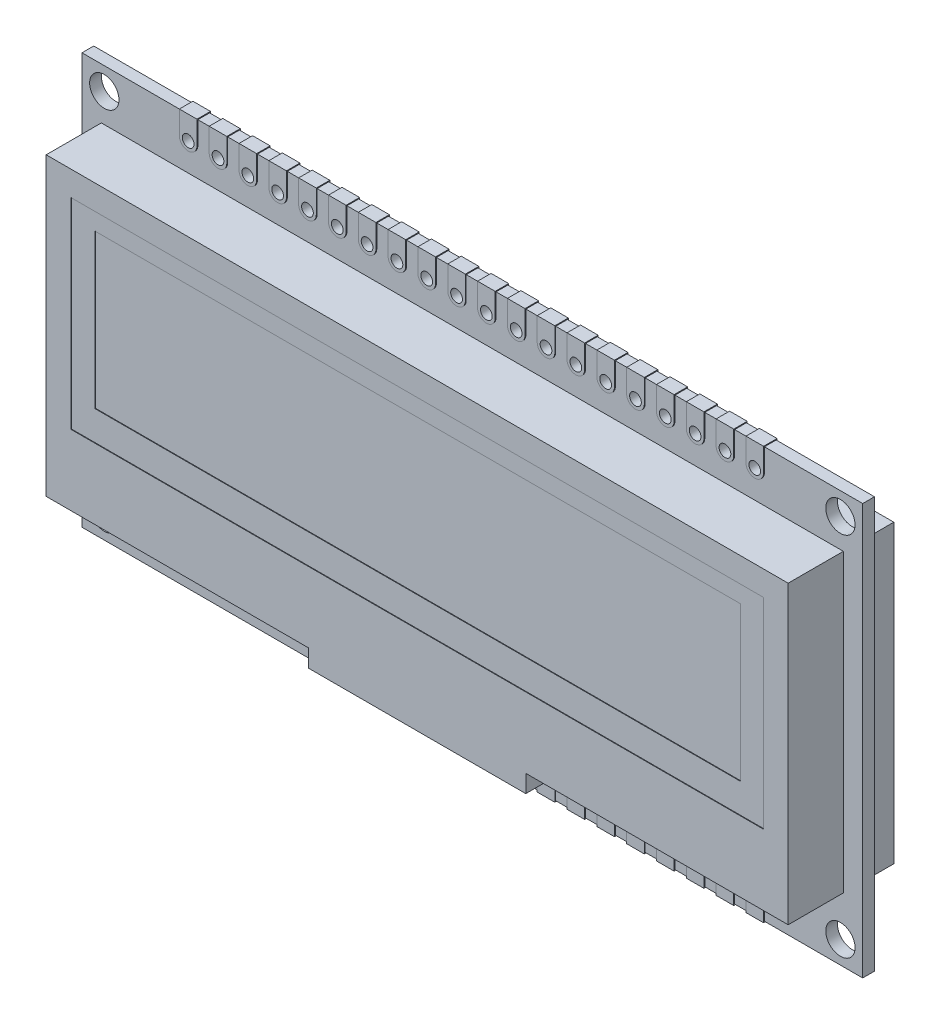
from build123d import *

# Parameters (mm, degrees)
SKETCH1_W           = 66.5
SKETCH1_H           = 35
SKETCH1_R           = 1.25
BOSS_EXTRUDE1_DEPTH = 0.5
SKETCH3_R           = 0.5
CUT_EXTRUDE1_DEPTH  = 1
SKETCH4_R           = 0.5
BOSS_EXTRUDE3_DEPTH = 0.575
BOSS_EXTRUDE2_DEPTH = 4.7
SKETCH5_W           = 59
SKETCH5_H           = 17.1
CUT_EXTRUDE2_DEPTH  = 0.05
SKETCH6_W           = 55.018
SKETCH6_H           = 13.098
CUT_EXTRUDE3_DEPTH  = 0.05
SKETCH7_W           = 63.2
SKETCH7_H           = 25.2
BOSS_EXTRUDE4_DEPTH = 3.3
CUT_EXTRUDE4_DEPTH  = 0.05


with BuildPart() as part:
    # Sketch1 → Boss-Extrude1 (new body, symmetric)
    with BuildSketch(Plane.XY):
        Rectangle(SKETCH1_W, SKETCH1_H)
        with Locations((-31.35, 15.6)):
            Circle(SKETCH1_R, mode=Mode.SUBTRACT)
        with Locations((-31.35, -15.6)):
            Circle(SKETCH1_R, mode=Mode.SUBTRACT)
        with Locations((31.35, 15.6)):
            Circle(SKETCH1_R, mode=Mode.SUBTRACT)
        with Locations((31.35, -15.6)):
            Circle(SKETCH1_R, mode=Mode.SUBTRACT)
    extrude(amount=BOSS_EXTRUDE1_DEPTH, both=True)

    # Sketch3 → Cut-Extrude1 (cut)
    with BuildSketch(Plane.XY.offset(0.5)):
        with Locations((-24.13, 15.6)):
            Circle(SKETCH3_R)
        with Locations((-21.59, 15.6)):
            Circle(SKETCH3_R)
        with Locations((-19.05, 15.6)):
            Circle(SKETCH3_R)
        with Locations((-16.51, 15.6)):
            Circle(SKETCH3_R)
        with Locations((-13.97, 15.6)):
            Circle(SKETCH3_R)
        with Locations((-11.43, 15.6)):
            Circle(SKETCH3_R)
        with Locations((-8.89, 15.6)):
            Circle(SKETCH3_R)
        with Locations((-6.35, 15.6)):
            Circle(SKETCH3_R)
        with Locations((-3.81, 15.6)):
            Circle(SKETCH3_R)
        with Locations((-1.27, 15.6)):
            Circle(SKETCH3_R)
        with Locations((1.27, 15.6)):
            Circle(SKETCH3_R)
        with Locations((3.81, 15.6)):
            Circle(SKETCH3_R)
        with Locations((6.35, 15.6)):
            Circle(SKETCH3_R)
        with Locations((8.89, 15.6)):
            Circle(SKETCH3_R)
        with Locations((11.43, 15.6)):
            Circle(SKETCH3_R)
        with Locations((13.97, 15.6)):
            Circle(SKETCH3_R)
        with Locations((16.51, 15.6)):
            Circle(SKETCH3_R)
        with Locations((19.05, 15.6)):
            Circle(SKETCH3_R)
        with Locations((21.59, 15.6)):
            Circle(SKETCH3_R)
        with Locations((24.13, 15.6)):
            Circle(SKETCH3_R)
        with Locations((24.13, -15.6)):
            Circle(SKETCH3_R)
        with Locations((21.59, -15.6)):
            Circle(SKETCH3_R)
        with Locations((19.05, -15.6)):
            Circle(SKETCH3_R)
        with Locations((16.51, -15.6)):
            Circle(SKETCH3_R)
        with Locations((13.97, -15.6)):
            Circle(SKETCH3_R)
        with Locations((11.43, -15.6)):
            Circle(SKETCH3_R)
        with Locations((8.89, -15.6)):
            Circle(SKETCH3_R)
        with Locations((6.35, -15.6)):
            Circle(SKETCH3_R)
    extrude(amount=-CUT_EXTRUDE1_DEPTH, mode=Mode.SUBTRACT)

    # Sketch4 → Boss-Extrude3 (add, symmetric)
    with BuildSketch(Plane.XY):
        with BuildLine():
            Line((-24.88, 15.6), (-24.88, 17.575))
            Line((-24.88, 17.575), (-23.38, 17.575))
            Line((-23.38, 17.575), (-23.38, 15.6))
            ThreePointArc((-23.38, 15.6), (-24.13, 14.85), (-24.88, 15.6))
        make_face()
        with Locations((-24.13, 15.6)):
            Circle(SKETCH4_R, mode=Mode.SUBTRACT)
        with BuildLine():
            Line((-22.34, 15.6), (-22.34, 17.575))
            Line((-22.34, 17.575), (-20.84, 17.575))
            Line((-20.84, 17.575), (-20.84, 15.6))
            ThreePointArc((-20.84, 15.6), (-21.59, 14.85), (-22.34, 15.6))
        make_face()
        with Locations((-21.59, 15.6)):
            Circle(SKETCH4_R, mode=Mode.SUBTRACT)
        with BuildLine():
            Line((-19.8, 15.6), (-19.8, 17.575))
            Line((-19.8, 17.575), (-18.3, 17.575))
            Line((-18.3, 17.575), (-18.3, 15.6))
            ThreePointArc((-18.3, 15.6), (-19.05, 14.85), (-19.8, 15.6))
        make_face()
        with Locations((-19.05, 15.6)):
            Circle(SKETCH4_R, mode=Mode.SUBTRACT)
        with BuildLine():
            Line((-17.26, 15.6), (-17.26, 17.575))
            Line((-17.26, 17.575), (-15.76, 17.575))
            Line((-15.76, 17.575), (-15.76, 15.6))
            ThreePointArc((-15.76, 15.6), (-16.51, 14.85), (-17.26, 15.6))
        make_face()
        with Locations((-16.51, 15.6)):
            Circle(SKETCH4_R, mode=Mode.SUBTRACT)
        with BuildLine():
            Line((-14.72, 15.6), (-14.72, 17.575))
            Line((-14.72, 17.575), (-13.22, 17.575))
            Line((-13.22, 17.575), (-13.22, 15.6))
            ThreePointArc((-13.22, 15.6), (-13.97, 14.85), (-14.72, 15.6))
        make_face()
        with Locations((-13.97, 15.6)):
            Circle(SKETCH4_R, mode=Mode.SUBTRACT)
        with BuildLine():
            Line((-12.18, 15.6), (-12.18, 17.575))
            Line((-12.18, 17.575), (-10.68, 17.575))
            Line((-10.68, 17.575), (-10.68, 15.6))
            ThreePointArc((-10.68, 15.6), (-11.43, 14.85), (-12.18, 15.6))
        make_face()
        with Locations((-11.43, 15.6)):
            Circle(SKETCH4_R, mode=Mode.SUBTRACT)
        with BuildLine():
            Line((-9.64, 15.6), (-9.64, 17.575))
            Line((-9.64, 17.575), (-8.14, 17.575))
            Line((-8.14, 17.575), (-8.14, 15.6))
            ThreePointArc((-8.14, 15.6), (-8.89, 14.85), (-9.64, 15.6))
        make_face()
        with Locations((-8.89, 15.6)):
            Circle(SKETCH4_R, mode=Mode.SUBTRACT)
        with BuildLine():
            Line((-7.1, 15.6), (-7.1, 17.575))
            Line((-7.1, 17.575), (-5.6, 17.575))
            Line((-5.6, 17.575), (-5.6, 15.6))
            ThreePointArc((-5.6, 15.6), (-6.35, 14.85), (-7.1, 15.6))
        make_face()
        with Locations((-6.35, 15.6)):
            Circle(SKETCH4_R, mode=Mode.SUBTRACT)
        with BuildLine():
            Line((-4.56, 15.6), (-4.56, 17.575))
            Line((-4.56, 17.575), (-3.06, 17.575))
            Line((-3.06, 17.575), (-3.06, 15.6))
            ThreePointArc((-3.06, 15.6), (-3.81, 14.85), (-4.56, 15.6))
        make_face()
        with Locations((-3.81, 15.6)):
            Circle(SKETCH4_R, mode=Mode.SUBTRACT)
        with BuildLine():
            Line((-2.02, 15.6), (-2.02, 17.575))
            Line((-2.02, 17.575), (-0.52, 17.575))
            Line((-0.52, 17.575), (-0.52, 15.6))
            ThreePointArc((-0.52, 15.6), (-1.27, 14.85), (-2.02, 15.6))
        make_face()
        with Locations((-1.27, 15.6)):
            Circle(SKETCH4_R, mode=Mode.SUBTRACT)
        with BuildLine():
            Line((0.52, 15.6), (0.52, 17.575))
            Line((0.52, 17.575), (2.02, 17.575))
            Line((2.02, 17.575), (2.02, 15.6))
            ThreePointArc((2.02, 15.6), (1.27, 14.85), (0.52, 15.6))
        make_face()
        with Locations((1.27, 15.6)):
            Circle(SKETCH4_R, mode=Mode.SUBTRACT)
        with BuildLine():
            Line((3.06, 15.6), (3.06, 17.575))
            Line((3.06, 17.575), (4.56, 17.575))
            Line((4.56, 17.575), (4.56, 15.6))
            ThreePointArc((4.56, 15.6), (3.81, 14.85), (3.06, 15.6))
        make_face()
        with Locations((3.81, 15.6)):
            Circle(SKETCH4_R, mode=Mode.SUBTRACT)
        with BuildLine():
            Line((5.6, 15.6), (5.6, 17.575))
            Line((5.6, 17.575), (7.1, 17.575))
            Line((7.1, 17.575), (7.1, 15.6))
            ThreePointArc((7.1, 15.6), (6.35, 14.85), (5.6, 15.6))
        make_face()
        with Locations((6.35, 15.6)):
            Circle(SKETCH4_R, mode=Mode.SUBTRACT)
        with BuildLine():
            Line((8.14, 15.6), (8.14, 17.575))
            Line((8.14, 17.575), (9.64, 17.575))
            Line((9.64, 17.575), (9.64, 15.6))
            ThreePointArc((9.64, 15.6), (8.89, 14.85), (8.14, 15.6))
        make_face()
        with Locations((8.89, 15.6)):
            Circle(SKETCH4_R, mode=Mode.SUBTRACT)
        with BuildLine():
            Line((10.68, 15.6), (10.68, 17.575))
            Line((10.68, 17.575), (12.18, 17.575))
            Line((12.18, 17.575), (12.18, 15.6))
            ThreePointArc((12.18, 15.6), (11.43, 14.85), (10.68, 15.6))
        make_face()
        with Locations((11.43, 15.6)):
            Circle(SKETCH4_R, mode=Mode.SUBTRACT)
        with BuildLine():
            Line((13.22, 15.6), (13.22, 17.575))
            Line((13.22, 17.575), (14.72, 17.575))
            Line((14.72, 17.575), (14.72, 15.6))
            ThreePointArc((14.72, 15.6), (13.97, 14.85), (13.22, 15.6))
        make_face()
        with Locations((13.97, 15.6)):
            Circle(SKETCH4_R, mode=Mode.SUBTRACT)
        with BuildLine():
            Line((15.76, 15.6), (15.76, 17.575))
            Line((15.76, 17.575), (17.26, 17.575))
            Line((17.26, 17.575), (17.26, 15.6))
            ThreePointArc((17.26, 15.6), (16.51, 14.85), (15.76, 15.6))
        make_face()
        with Locations((16.51, 15.6)):
            Circle(SKETCH4_R, mode=Mode.SUBTRACT)
        with BuildLine():
            Line((18.3, 15.6), (18.3, 17.575))
            Line((18.3, 17.575), (19.8, 17.575))
            Line((19.8, 17.575), (19.8, 15.6))
            ThreePointArc((19.8, 15.6), (19.05, 14.85), (18.3, 15.6))
        make_face()
        with Locations((19.05, 15.6)):
            Circle(SKETCH4_R, mode=Mode.SUBTRACT)
        with BuildLine():
            Line((20.84, 15.6), (20.84, 17.575))
            Line((20.84, 17.575), (22.34, 17.575))
            Line((22.34, 17.575), (22.34, 15.6))
            ThreePointArc((22.34, 15.6), (21.59, 14.85), (20.84, 15.6))
        make_face()
        with Locations((21.59, 15.6)):
            Circle(SKETCH4_R, mode=Mode.SUBTRACT)
        with BuildLine():
            Line((23.38, 15.6), (23.38, 17.575))
            Line((23.38, 17.575), (24.88, 17.575))
            Line((24.88, 17.575), (24.88, 15.6))
            ThreePointArc((24.88, 15.6), (24.13, 14.85), (23.38, 15.6))
        make_face()
        with Locations((24.13, 15.6)):
            Circle(SKETCH4_R, mode=Mode.SUBTRACT)
        with BuildLine():
            Line((24.88, -15.6), (24.88, -17.575))
            Line((24.88, -17.575), (23.38, -17.575))
            Line((23.38, -17.575), (23.38, -15.6))
            ThreePointArc((23.38, -15.6), (24.13, -14.85), (24.88, -15.6))
        make_face()
        with Locations((24.13, -15.6)):
            Circle(SKETCH4_R, mode=Mode.SUBTRACT)
        with BuildLine():
            Line((22.34, -15.6), (22.34, -17.575))
            Line((22.34, -17.575), (20.84, -17.575))
            Line((20.84, -17.575), (20.84, -15.6))
            ThreePointArc((20.84, -15.6), (21.59, -14.85), (22.34, -15.6))
        make_face()
        with Locations((21.59, -15.6)):
            Circle(SKETCH4_R, mode=Mode.SUBTRACT)
        with BuildLine():
            Line((19.8, -15.6), (19.8, -17.575))
            Line((19.8, -17.575), (18.3, -17.575))
            Line((18.3, -17.575), (18.3, -15.6))
            ThreePointArc((18.3, -15.6), (19.05, -14.85), (19.8, -15.6))
        make_face()
        with Locations((19.05, -15.6)):
            Circle(SKETCH4_R, mode=Mode.SUBTRACT)
        with BuildLine():
            Line((17.26, -15.6), (17.26, -17.575))
            Line((17.26, -17.575), (15.76, -17.575))
            Line((15.76, -17.575), (15.76, -15.6))
            ThreePointArc((15.76, -15.6), (16.51, -14.85), (17.26, -15.6))
        make_face()
        with Locations((16.51, -15.6)):
            Circle(SKETCH4_R, mode=Mode.SUBTRACT)
        with BuildLine():
            Line((14.72, -15.6), (14.72, -17.575))
            Line((14.72, -17.575), (13.22, -17.575))
            Line((13.22, -17.575), (13.22, -15.6))
            ThreePointArc((13.22, -15.6), (13.97, -14.85), (14.72, -15.6))
        make_face()
        with Locations((13.97, -15.6)):
            Circle(SKETCH4_R, mode=Mode.SUBTRACT)
        with BuildLine():
            Line((12.18, -15.6), (12.18, -17.575))
            Line((12.18, -17.575), (10.68, -17.575))
            Line((10.68, -17.575), (10.68, -15.6))
            ThreePointArc((10.68, -15.6), (11.43, -14.85), (12.18, -15.6))
        make_face()
        with Locations((11.43, -15.6)):
            Circle(SKETCH4_R, mode=Mode.SUBTRACT)
        with BuildLine():
            Line((9.64, -15.6), (9.64, -17.575))
            Line((9.64, -17.575), (8.14, -17.575))
            Line((8.14, -17.575), (8.14, -15.6))
            ThreePointArc((8.14, -15.6), (8.89, -14.85), (9.64, -15.6))
        make_face()
        with Locations((8.89, -15.6)):
            Circle(SKETCH4_R, mode=Mode.SUBTRACT)
        with BuildLine():
            Line((7.1, -15.6), (7.1, -17.575))
            Line((7.1, -17.575), (5.6, -17.575))
            Line((5.6, -17.575), (5.6, -15.6))
            ThreePointArc((5.6, -15.6), (6.35, -14.85), (7.1, -15.6))
        make_face()
        with Locations((6.35, -15.6)):
            Circle(SKETCH4_R, mode=Mode.SUBTRACT)
    extrude(amount=BOSS_EXTRUDE3_DEPTH, both=True)

    # Sketch7 → Boss-Extrude4 (add)
    with BuildSketch(Plane(origin=(0, 0, -0.5), x_dir=(-1, 0, 0), z_dir=(0, 0, -1))):
        with Locations((0, 0.55)):
            Rectangle(SKETCH7_W, SKETCH7_H)
    extrude(amount=BOSS_EXTRUDE4_DEPTH)

    # Sketch8 → Cut-Extrude4 (cut)
    with BuildSketch(Plane(origin=(0, 0, -3.8), x_dir=(-1, 0, 0), z_dir=(0, 0, -1))):
        Polygon((-15.834294872, 1.797396647), (-15.264423077, 1.797396647), (-15.264423077, 0.679913675), (-14.363822115, 1.797396647), (-13.644486178, 1.797396647), (-14.775961538, 0.393069724), (-13.534455128, -1.377603353), (-14.220718149, -1.377603353), (-15.264423077, 0.111313915), (-15.264423077, -1.377603353), (-15.834294872, -1.377603353), align=None)
        Polygon((-13.107051282, 1.797396647), (-11.397435897, 1.797396647), (-11.397435897, 1.227524853), (-12.537179487, 1.227524853), (-12.537179487, 0.616947929), (-11.397435897, 0.616947929), (-11.397435897, 0.047076135), (-12.537179487, 0.047076135), (-12.537179487, -0.807731558), (-11.397435897, -0.807731558), (-11.397435897, -1.377603353), (-13.107051282, -1.377603353), align=None)
        Polygon((-10.827564103, 1.797396647), (-9.117948718, 1.797396647), (-9.117948718, 1.227524853), (-10.257692308, 1.227524853), (-10.257692308, 0.616947929), (-9.117948718, 0.616947929), (-9.117948718, 0.047076135), (-10.257692308, 0.047076135), (-10.257692308, -0.807731558), (-9.117948718, -0.807731558), (-9.117948718, -1.377603353), (-10.827564103, -1.377603353), align=None)
        with BuildLine():
            Line((-8.548076923, 1.797396647), (-7.912059295, 1.797396647))
            add(Edge.make_bspline(
                [(-7.912059295, 1.797396647), (-7.870502728, 1.797210631), (-7.7903314, 1.796851767), (-7.674717749, 1.792500065), (-7.568058495, 1.784701549), (-7.470378144, 1.775063817), (-7.381716857, 1.761552091), (-7.301963607, 1.746061955), (-7.23110184, 1.727190461), (-7.168332487, 1.70479026), (-7.111999019, 1.678381298), (-7.05868939, 1.650253868), (-7.009608402, 1.616684772), (-6.96227879, 1.581291946), (-6.919406469, 1.540694325), (-6.878316808, 1.49759374), (-6.840750065, 1.450280858), (-6.806532171, 1.399328389), (-6.775491268, 1.345677715), (-6.748371858, 1.289232926), (-6.726374112, 1.229904704), (-6.707920738, 1.168076834), (-6.693098809, 1.103752012), (-6.683232861, 1.036534634), (-6.676531412, 0.966894037), (-6.675940102, 0.919496603), (-6.675641026, 0.895523651)],
                knots=[0, 0, 0, 0, 0.000124666, 0.000240507, 0.000346996, 0.000445469, 0.000534879, 0.000615956, 0.000689087, 0.000754674, 0.000815576, 0.000875625, 0.000935248, 0.000993765, 0.001052722, 0.001112114, 0.001172308, 0.001233696, 0.001296097, 0.001358115, 0.001421314, 0.001485706, 0.001551589, 0.001619141, 0.001689392, 0.001761287, 0.001761287, 0.001761287, 0.001761287], degree=3))
            add(Edge.make_bspline(
                [(-6.675641026, 0.895523651), (-6.676073752, 0.869002944), (-6.676924112, 0.816886497), (-6.685260379, 0.74049018), (-6.699501358, 0.667653209), (-6.718113573, 0.597761335), (-6.744066982, 0.531964437), (-6.773717534, 0.468692578), (-6.810197117, 0.409719709), (-6.851880873, 0.354308149), (-6.897404289, 0.302007377), (-6.947848091, 0.254327478), (-7.002250797, 0.21094342), (-7.06029749, 0.171400535), (-7.122206094, 0.135778589), (-7.187931939, 0.103744021), (-7.257923839, 0.076321396), (-7.306664092, 0.061979585), (-7.3313752, 0.054708346)],
                knots=[0, 0, 0, 0, 7.9543e-05, 0.000156312, 0.000230155, 0.000302059, 0.000372929, 0.000442056, 0.000511431, 0.000580503, 0.000649908, 0.00071919, 0.000788422, 0.000858457, 0.000929693, 0.001002514, 0.001077631, 0.001154881, 0.001154881, 0.001154881, 0.001154881], degree=3))
            add(Edge.make_bspline(
                [(-7.3313752, 0.054708346), (-7.347651358, 0.050658812), (-7.382910756, 0.041886216), (-7.441255376, 0.03297983), (-7.508491425, 0.024790956), (-7.58483632, 0.017753609), (-7.670334077, 0.012969854), (-7.764901911, 0.009233953), (-7.868582679, 0.006517568), (-7.940678185, 0.006421179), (-7.978205128, 0.006371006)],
                knots=[0, 0, 0, 0, 5.0294e-05, 0.000108952, 0.000176875, 0.000253517, 0.000338896, 0.000433739, 0.000537441, 0.000650018, 0.000650018, 0.000650018, 0.000650018], degree=3))
            Line((-7.978205128, 0.006371006), (-7.978205128, -1.377603353))
            Line((-7.978205128, -1.377603353), (-8.548076923, -1.377603353))
            Line((-8.548076923, -1.377603353), (-8.548076923, 1.797396647))
        make_face()
        with BuildLine():
            Line((-7.978205128, 0.576242801), (-7.77658754, 0.576242801))
            add(Edge.make_bspline(
                [(-7.77658754, 0.576242801), (-7.739900037, 0.576475429), (-7.672394486, 0.576903466), (-7.580205742, 0.583093138), (-7.506121093, 0.592546018), (-7.447592846, 0.606103634), (-7.40137925, 0.626679112), (-7.361522918, 0.650481064), (-7.327337124, 0.68057798), (-7.297737258, 0.714968856), (-7.274073057, 0.754485697), (-7.257663166, 0.798485046), (-7.247003624, 0.846042432), (-7.246019116, 0.879139224), (-7.245512821, 0.896159668)],
                knots=[0, 0, 0, 0, 0.000110048, 0.000202489, 0.000276966, 0.000334041, 0.000381895, 0.000428145, 0.00047278, 0.000517897, 0.000563818, 0.000610121, 0.000658274, 0.000709254, 0.000709254, 0.000709254, 0.000709254], degree=3))
            add(Edge.make_bspline(
                [(-7.245512821, 0.896159668), (-7.246013908, 0.911030209), (-7.246986139, 0.939882632), (-7.254128408, 0.981523836), (-7.265511131, 1.020342028), (-7.28200426, 1.055931803), (-7.303325969, 1.08823269), (-7.329321448, 1.117231964), (-7.359657123, 1.143550667), (-7.383078037, 1.157481559), (-7.394976963, 1.164559107)],
                knots=[0, 0, 0, 0, 4.4594e-05, 8.6523e-05, 0.000126364, 0.000165633, 0.000203735, 0.000242029, 0.000282179, 0.000323642, 0.000323642, 0.000323642, 0.000323642], degree=3))
            add(Edge.make_bspline(
                [(-7.394976963, 1.164559107), (-7.40505604, 1.169656386), (-7.426395511, 1.180448368), (-7.4627387, 1.192994837), (-7.504678185, 1.203579166), (-7.552497104, 1.212364056), (-7.606004695, 1.219182043), (-7.665191411, 1.224396098), (-7.73014435, 1.226492873), (-7.775315233, 1.227171371), (-7.798848157, 1.227524853)],
                knots=[0, 0, 0, 0, 3.3853e-05, 7.1673e-05, 0.00011502, 0.000163546, 0.000217427, 0.000276795, 0.000341719, 0.000412328, 0.000412328, 0.000412328, 0.000412328], degree=3))
            Line((-7.798848157, 1.227524853), (-7.978205128, 1.227524853))
            Line((-7.978205128, 1.227524853), (-7.978205128, 0.576242801))
        make_face(mode=Mode.SUBTRACT)
        with BuildLine():
            add(Edge.make_bspline(
                [(-3.392518029, 1.878806904), (-3.337316763, 1.877377644), (-3.22833696, 1.874555962), (-3.068066998, 1.851035038), (-2.913617256, 1.812711065), (-2.765057574, 1.759437971), (-2.622759931, 1.689772848), (-2.486222395, 1.605690751), (-2.355934036, 1.505604678), (-2.233229945, 1.391849473), (-2.119829234, 1.268145655), (-2.021567453, 1.134956503), (-1.93777341, 0.99573308), (-1.868324683, 0.850102333), (-1.815426551, 0.697055701), (-1.778305744, 0.537373519), (-1.754457465, 0.371101215), (-1.751714546, 0.257892439), (-1.750320513, 0.200356383)],
                knots=[0, 0, 0, 0, 0.000165541, 0.000326815, 0.000484774, 0.000642302, 0.00079932, 0.000959238, 0.001122574, 0.001291359, 0.001460652, 0.001625256, 0.001787016, 0.001947474, 0.002108388, 0.00227176, 0.002438702, 0.002611232, 0.002611232, 0.002611232, 0.002611232], degree=3))
            add(Edge.make_bspline(
                [(-1.750320513, 0.200356383), (-1.751805097, 0.143468626), (-1.754730519, 0.031369475), (-1.777332153, -0.133370565), (-1.815078079, -0.291342218), (-1.867079017, -0.442903057), (-1.935268207, -0.587318975), (-2.017428174, -0.725512045), (-2.115726965, -0.856199803), (-2.226579237, -0.979312118), (-2.348617968, -1.091062961), (-2.477876357, -1.189543198), (-2.61375757, -1.272991634), (-2.756062719, -1.341370047), (-2.905096971, -1.394436015), (-3.060492193, -1.431877911), (-3.222238769, -1.454632107), (-3.332234285, -1.45753842), (-3.388065905, -1.459013609)],
                knots=[0, 0, 0, 0, 0.000170624, 0.000336219, 0.000497735, 0.000657239, 0.000816004, 0.000976019, 0.001138712, 0.001305782, 0.001472338, 0.001634398, 0.001792566, 0.00194988, 0.002107193, 0.002266236, 0.002428681, 0.002596127, 0.002596127, 0.002596127, 0.002596127], degree=3))
            add(Edge.make_bspline(
                [(-3.388065905, -1.459013609), (-3.446459086, -1.457690292), (-3.561193704, -1.455090154), (-3.729108332, -1.430364035), (-3.889985054, -1.393117862), (-4.042472413, -1.337529947), (-4.188123364, -1.268040379), (-4.325867765, -1.182459809), (-4.455659326, -1.080929667), (-4.576753541, -0.966050177), (-4.686465193, -0.840346818), (-4.783307245, -0.707552366), (-4.864995665, -0.568681255), (-4.931533441, -0.423668489), (-4.98398915, -0.273415288), (-5.020990693, -0.117006567), (-5.042848388, 0.045182551), (-5.045893038, 0.155344642), (-5.047435897, 0.211168683)],
                knots=[0, 0, 0, 0, 0.000175071, 0.000343991, 0.000508129, 0.000669679, 0.000829837, 0.000991505, 0.001155115, 0.001323375, 0.001491502, 0.001654978, 0.001815764, 0.001973993, 0.002132895, 0.002292408, 0.002455397, 0.002622844, 0.002622844, 0.002622844, 0.002622844], degree=3))
            add(Edge.make_bspline(
                [(-5.047435897, 0.211168683), (-5.046951659, 0.248724175), (-5.045989314, 0.323359621), (-5.034396855, 0.433965543), (-5.017707046, 0.542412586), (-4.993023611, 0.648268369), (-4.963039547, 0.752279657), (-4.924190955, 0.853478286), (-4.879970745, 0.952945337), (-4.828303593, 1.049505978), (-4.770854715, 1.142271771), (-4.708172875, 1.230805124), (-4.64010046, 1.314035539), (-4.566856753, 1.392509973), (-4.488189347, 1.465712606), (-4.40513303, 1.534679724), (-4.316076993, 1.597579315), (-4.222970394, 1.655947513), (-4.126338146, 1.708728862), (-4.02657363, 1.753654768), (-3.925732192, 1.792887796), (-3.822466726, 1.823852237), (-3.717883907, 1.84907245), (-3.610866477, 1.86575101), (-3.502381279, 1.877343148), (-3.429226021, 1.878317827), (-3.392518029, 1.878806904)],
                knots=[0, 0, 0, 0, 0.00011262, 0.000223814, 0.000333292, 0.000441602, 0.000549675, 0.000657762, 0.000766512, 0.000876056, 0.000986016, 0.001093666, 0.001201246, 0.001308342, 0.001415439, 0.001523422, 0.001631959, 0.001742255, 0.001852962, 0.001961973, 0.002070287, 0.002177323, 0.002285158, 0.002392752, 0.002502047, 0.002612124, 0.002612124, 0.002612124, 0.002612124], degree=3))
        make_face()
        with BuildLine():
            add(Edge.make_bspline(
                [(-3.401422276, 1.308935109), (-3.43857272, 1.307938279), (-3.511892832, 1.305970936), (-3.619440084, 1.290982441), (-3.722689243, 1.267044112), (-3.821067959, 1.232369735), (-3.915002614, 1.188238052), (-4.004659726, 1.134803267), (-4.088797728, 1.070228617), (-4.168538519, 0.997980829), (-4.240571202, 0.917480188), (-4.30421435, 0.831210062), (-4.357473414, 0.739314518), (-4.402078214, 0.642647246), (-4.435655742, 0.540121247), (-4.459572009, 0.432539619), (-4.474686197, 0.319716993), (-4.476591359, 0.242805956), (-4.477564103, 0.203536471)],
                knots=[0, 0, 0, 0, 0.000111419, 0.000219897, 0.00032511, 0.000428903, 0.000532185, 0.000636026, 0.000741351, 0.00084985, 0.000958393, 0.001064868, 0.001170898, 0.001276489, 0.001383689, 0.00149386, 0.001606751, 0.001724524, 0.001724524, 0.001724524, 0.001724524], degree=3))
            add(Edge.make_bspline(
                [(-4.477564103, 0.203536471), (-4.476274393, 0.160017049), (-4.473746775, 0.074726192), (-4.455962151, -0.049693812), (-4.42553443, -0.167196158), (-4.381597392, -0.277206158), (-4.327103938, -0.380945391), (-4.259431716, -0.477142386), (-4.179676697, -0.566373125), (-4.118234076, -0.618469747), (-4.087049279, -0.644911045)],
                knots=[0, 0, 0, 0, 0.000130539, 0.000255834, 0.000376163, 0.000493797, 0.00061045, 0.000726904, 0.0008458, 0.000968339, 0.000968339, 0.000968339, 0.000968339], degree=3))
            add(Edge.make_bspline(
                [(-4.087049279, -0.644911045), (-4.061502976, -0.66444486), (-4.010985933, -0.70307239), (-3.930349735, -0.752581494), (-3.847310328, -0.795015735), (-3.761241077, -0.829302099), (-3.672323755, -0.856271177), (-3.580570556, -0.875157179), (-3.486111487, -0.887009779), (-3.422233837, -0.888426389), (-3.389973958, -0.889141814)],
                knots=[0, 0, 0, 0, 9.6423e-05, 0.000190674, 0.000283402, 0.000375879, 0.000468233, 0.000561786, 0.00065661, 0.00075336, 0.00075336, 0.00075336, 0.00075336], degree=3))
            add(Edge.make_bspline(
                [(-3.389973958, -0.889141814), (-3.353462316, -0.888136532), (-3.281624512, -0.886158609), (-3.176079311, -0.871354631), (-3.074963803, -0.846300955), (-2.977650254, -0.811930754), (-2.884419272, -0.76724496), (-2.795726504, -0.712152795), (-2.711416447, -0.64733072), (-2.631777245, -0.574134159), (-2.558983249, -0.493316402), (-2.495472911, -0.40658612), (-2.440520475, -0.315854239), (-2.396843233, -0.219836589), (-2.361939132, -0.119439531), (-2.33831071, -0.014218427), (-2.323068842, 0.09539296), (-2.321163143, 0.169987383), (-2.320192308, 0.207988595)],
                knots=[0, 0, 0, 0, 0.000109513, 0.000215471, 0.000318978, 0.000421572, 0.000524552, 0.000628511, 0.000734222, 0.00084315, 0.000952591, 0.001059956, 0.001165215, 0.001270227, 0.001375823, 0.001483513, 0.001593251, 0.001707212, 0.001707212, 0.001707212, 0.001707212], degree=3))
            add(Edge.make_bspline(
                [(-2.320192308, 0.207988595), (-2.321196734, 0.245771289), (-2.323173793, 0.32014076), (-2.338003827, 0.429470337), (-2.362898618, 0.53422692), (-2.39737203, 0.634581588), (-2.441392751, 0.730632725), (-2.495828839, 0.822042559), (-2.560489283, 0.908722719), (-2.633885929, 0.990082512), (-2.713773666, 1.064846951), (-2.799541134, 1.129728893), (-2.888788463, 1.186109237), (-2.983563423, 1.230275323), (-3.081926996, 1.265462349), (-3.184479403, 1.291374581), (-3.291609067, 1.305865641), (-3.364491592, 1.307902833), (-3.401422276, 1.308935109)],
                knots=[0, 0, 0, 0, 0.000113325, 0.000223064, 0.000330279, 0.000435876, 0.000540888, 0.000646693, 0.000754435, 0.000864775, 0.000975033, 0.001082142, 0.001186976, 0.001291105, 0.001395111, 0.001500005, 0.001607853, 0.001718637, 0.001718637, 0.001718637, 0.001718637], degree=3))
        make_face(mode=Mode.SUBTRACT)
        with BuildLine():
            Line((-1.180448718, 1.797396647), (-0.610576923, 1.797396647))
            Line((-0.610576923, 1.797396647), (-0.610576923, -0.268388609))
            add(Edge.make_bspline(
                [(-0.610576923, -0.268388609), (-0.610545936, -0.289805775), (-0.610486086, -0.331172809), (-0.607489927, -0.390520959), (-0.604748236, -0.445074335), (-0.599801447, -0.494773212), (-0.592493343, -0.539638851), (-0.585416715, -0.579959452), (-0.575839198, -0.615013121), (-0.56144572, -0.654913373), (-0.539270097, -0.699743485), (-0.503036359, -0.746466456), (-0.461225725, -0.78910795), (-0.411113272, -0.824601113), (-0.354791307, -0.853311883), (-0.292569294, -0.874583386), (-0.224534943, -0.886407517), (-0.177492921, -0.888212687), (-0.153280248, -0.889141814)],
                knots=[0, 0, 0, 0, 6.4241e-05, 0.000124081, 0.000178236, 0.000228105, 0.000273801, 0.000314591, 0.000350849, 0.000382638, 0.000441801, 0.000499933, 0.000559298, 0.000620369, 0.000683231, 0.000748398, 0.00081689, 0.000889533, 0.000889533, 0.000889533, 0.000889533], degree=3))
            add(Edge.make_bspline(
                [(-0.153280248, -0.889141814), (-0.127557271, -0.888391199), (-0.077401821, -0.886927627), (-0.005261191, -0.87256108), (0.061577512, -0.849684618), (0.121699085, -0.817034076), (0.175043696, -0.777896679), (0.220198792, -0.733267782), (0.255835028, -0.683058373), (0.2790614, -0.63673637), (0.292101865, -0.594100999), (0.301876342, -0.556007914), (0.309042116, -0.511061844), (0.315543141, -0.459964719), (0.319449756, -0.402187271), (0.323685844, -0.338194154), (0.325238409, -0.26754751), (0.325503033, -0.218354926), (0.325641026, -0.192702511)],
                knots=[0, 0, 0, 0, 7.7087e-05, 0.000150306, 0.000219702, 0.00028828, 0.000354682, 0.000417645, 0.000477828, 0.0005387, 0.00057209, 0.000611425, 0.000656596, 0.000708504, 0.000765919, 0.00083027, 0.000900894, 0.000977854, 0.000977854, 0.000977854, 0.000977854], degree=3))
            Line((0.325641026, -0.192702511), (0.325641026, 1.797396647))
            Line((0.325641026, 1.797396647), (0.895512821, 1.797396647))
            Line((0.895512821, 1.797396647), (0.895512821, -0.096663849))
            add(Edge.make_bspline(
                [(0.895512821, -0.096663849), (0.895433683, -0.135037424), (0.895281511, -0.208826067), (0.892944595, -0.314865539), (0.887969723, -0.411715587), (0.883791405, -0.499404511), (0.875704928, -0.577814179), (0.867280716, -0.647279422), (0.856543333, -0.707554072), (0.840566753, -0.776169436), (0.812995906, -0.855177515), (0.768548085, -0.946151893), (0.712124454, -1.03522132), (0.645434542, -1.12140597), (0.570135531, -1.201468732), (0.487896961, -1.271753475), (0.400025399, -1.331206788), (0.30560265, -1.378374966), (0.204709072, -1.415162589), (0.096346399, -1.439882019), (-0.019411474, -1.456582776), (-0.099367625, -1.45818709), (-0.140559896, -1.459013609)],
                knots=[0, 0, 0, 0, 0.000115121, 0.000221366, 0.000318143, 0.000406061, 0.000484663, 0.000554558, 0.00061594, 0.000668237, 0.000765788, 0.0008662, 0.000971372, 0.001081543, 0.001192671, 0.001300497, 0.001405455, 0.001510128, 0.00161636, 0.001726816, 0.001843029, 0.001966521, 0.001966521, 0.001966521, 0.001966521], degree=3))
            add(Edge.make_bspline(
                [(-0.140559896, -1.459013609), (-0.16792886, -1.458552615), (-0.221927264, -1.457643083), (-0.301341391, -1.449623388), (-0.378110744, -1.437805374), (-0.452091075, -1.420564108), (-0.523539155, -1.398291612), (-0.592436003, -1.370875721), (-0.658525581, -1.338469357), (-0.721438061, -1.301370589), (-0.781096024, -1.261254657), (-0.835620323, -1.216784458), (-0.886887267, -1.17124873), (-0.933415775, -1.122731138), (-0.975555317, -1.071741033), (-1.013219108, -1.018162855), (-1.046351191, -0.962001363), (-1.075784986, -0.902244249), (-1.100977442, -0.835854275), (-1.122215629, -0.760469922), (-1.140769808, -0.674909616), (-1.15455818, -0.578980593), (-1.167058798, -0.472999026), (-1.174971001, -0.356688816), (-1.17911023, -0.230046626), (-1.179991281, -0.142248222), (-1.180448718, -0.096663849)],
                knots=[0, 0, 0, 0, 8.2086e-05, 0.000161953, 0.000239226, 0.000314976, 0.000389608, 0.000463542, 0.000537213, 0.000610189, 0.000682516, 0.000752643, 0.000821097, 0.00088812, 0.000954082, 0.001019369, 0.00108438, 0.001149519, 0.001218973, 0.001297076, 0.001384276, 0.001481422, 0.00158769, 0.001704375, 0.00183102, 0.001967778, 0.001967778, 0.001967778, 0.001967778], degree=3))
            Line((-1.180448718, -0.096663849), (-1.180448718, 1.797396647))
        make_face()
        Polygon((1.302564103, 1.797396647), (3.012179487, 1.797396647), (3.012179487, 1.227524853), (2.442307692, 1.227524853), (2.442307692, -1.377603353), (1.872435897, -1.377603353), (1.872435897, 1.227524853), (1.302564103, 1.227524853), align=None)
        Polygon((4.518269231, 1.797396647), (6.431410256, 1.797396647), (5.294210737, -0.807731558), (6.35, -0.807731558), (6.35, -1.377603353), (4.436858974, -1.377603353), (5.574694511, 1.227524853), (4.518269231, 1.227524853), align=None)
        with BuildLine():
            add(Edge.make_bspline(
                [(8.371264022, 1.878806904), (8.426465289, 1.877377644), (8.535445091, 1.874555962), (8.695715053, 1.851035038), (8.850164796, 1.812711065), (8.998724477, 1.759437971), (9.14102212, 1.689772848), (9.277559657, 1.605690751), (9.407848016, 1.505604678), (9.530552107, 1.391849473), (9.643952817, 1.268145655), (9.742214599, 1.134956503), (9.826008641, 0.99573308), (9.895457368, 0.850102333), (9.9483555, 0.697055701), (9.985476307, 0.537373519), (10.009324587, 0.371101215), (10.012067506, 0.257892439), (10.013461538, 0.200356383)],
                knots=[0, 0, 0, 0, 0.000165541, 0.000326815, 0.000484774, 0.000642302, 0.00079932, 0.000959238, 0.001122574, 0.001291359, 0.001460652, 0.001625256, 0.001787016, 0.001947474, 0.002108388, 0.00227176, 0.002438702, 0.002611232, 0.002611232, 0.002611232, 0.002611232], degree=3))
            add(Edge.make_bspline(
                [(10.013461538, 0.200356383), (10.011976954, 0.143468626), (10.009051532, 0.031369475), (9.986449898, -0.133370565), (9.948703972, -0.291342218), (9.896703034, -0.442903057), (9.828513845, -0.587318975), (9.746353877, -0.725512045), (9.648055086, -0.856199803), (9.537202814, -0.979312118), (9.415164084, -1.091062961), (9.285905694, -1.189543198), (9.150024482, -1.272991634), (9.007719333, -1.341370047), (8.858685081, -1.394436015), (8.703289859, -1.431877911), (8.541543282, -1.454632107), (8.431547766, -1.45753842), (8.375716146, -1.459013609)],
                knots=[0, 0, 0, 0, 0.000170624, 0.000336219, 0.000497735, 0.000657239, 0.000816004, 0.000976019, 0.001138712, 0.001305782, 0.001472338, 0.001634398, 0.001792566, 0.00194988, 0.002107193, 0.002266236, 0.002428681, 0.002596127, 0.002596127, 0.002596127, 0.002596127], degree=3))
            add(Edge.make_bspline(
                [(8.375716146, -1.459013609), (8.317322965, -1.457690292), (8.202588347, -1.455090154), (8.03467372, -1.430364035), (7.873796998, -1.393117862), (7.721309638, -1.337529947), (7.575658687, -1.268040379), (7.437914286, -1.182459809), (7.308122725, -1.080929667), (7.18702851, -0.966050177), (7.077316859, -0.840346818), (6.980474806, -0.707552366), (6.898786386, -0.568681255), (6.83224861, -0.423668489), (6.779792901, -0.273415288), (6.742791358, -0.117006567), (6.720933664, 0.045182551), (6.717889014, 0.155344642), (6.716346154, 0.211168683)],
                knots=[0, 0, 0, 0, 0.000175071, 0.000343991, 0.000508129, 0.000669679, 0.000829837, 0.000991505, 0.001155115, 0.001323375, 0.001491502, 0.001654978, 0.001815764, 0.001973993, 0.002132895, 0.002292408, 0.002455397, 0.002622844, 0.002622844, 0.002622844, 0.002622844], degree=3))
            add(Edge.make_bspline(
                [(6.716346154, 0.211168683), (6.716830392, 0.248724175), (6.717792737, 0.323359621), (6.729385197, 0.433965543), (6.746075005, 0.542412586), (6.77075844, 0.648268369), (6.800742505, 0.752279657), (6.839591096, 0.853478286), (6.883811306, 0.952945337), (6.935478458, 1.049505978), (6.992927336, 1.142271771), (7.055609176, 1.230805124), (7.123681591, 1.314035539), (7.196925298, 1.392509973), (7.275592705, 1.465712606), (7.358649022, 1.534679724), (7.447705058, 1.597579315), (7.540811657, 1.655947513), (7.637443905, 1.708728862), (7.737208422, 1.753654768), (7.838049859, 1.792887796), (7.941315325, 1.823852237), (8.045898145, 1.84907245), (8.152915574, 1.86575101), (8.261400772, 1.877343148), (8.33455603, 1.878317827), (8.371264022, 1.878806904)],
                knots=[0, 0, 0, 0, 0.00011262, 0.000223814, 0.000333292, 0.000441602, 0.000549675, 0.000657762, 0.000766512, 0.000876056, 0.000986016, 0.001093666, 0.001201246, 0.001308342, 0.001415439, 0.001523422, 0.001631959, 0.001742255, 0.001852962, 0.001961973, 0.002070287, 0.002177323, 0.002285158, 0.002392752, 0.002502047, 0.002612124, 0.002612124, 0.002612124, 0.002612124], degree=3))
        make_face()
        with BuildLine():
            add(Edge.make_bspline(
                [(8.362359776, 1.308935109), (8.325209331, 1.307938279), (8.251889219, 1.305970936), (8.144341968, 1.290982441), (8.041092808, 1.267044112), (7.942714092, 1.232369735), (7.848779437, 1.188238052), (7.759122325, 1.134803267), (7.674984324, 1.070228617), (7.595243533, 0.997980829), (7.523210849, 0.917480188), (7.459567701, 0.831210062), (7.406308637, 0.739314518), (7.361703838, 0.642647246), (7.328126309, 0.540121247), (7.304210043, 0.432539619), (7.289095855, 0.319716993), (7.287190693, 0.242805956), (7.286217949, 0.203536471)],
                knots=[0, 0, 0, 0, 0.000111419, 0.000219897, 0.00032511, 0.000428903, 0.000532185, 0.000636026, 0.000741351, 0.00084985, 0.000958393, 0.001064868, 0.001170898, 0.001276489, 0.001383689, 0.00149386, 0.001606751, 0.001724524, 0.001724524, 0.001724524, 0.001724524], degree=3))
            add(Edge.make_bspline(
                [(7.286217949, 0.203536471), (7.287507659, 0.160017049), (7.290035276, 0.074726192), (7.3078199, -0.049693812), (7.338247621, -0.167196158), (7.382184659, -0.277206158), (7.436678114, -0.380945391), (7.504350335, -0.477142386), (7.584105354, -0.566373125), (7.645547975, -0.618469747), (7.676732772, -0.644911045)],
                knots=[0, 0, 0, 0, 0.000130539, 0.000255834, 0.000376163, 0.000493797, 0.00061045, 0.000726904, 0.0008458, 0.000968339, 0.000968339, 0.000968339, 0.000968339], degree=3))
            add(Edge.make_bspline(
                [(7.676732772, -0.644911045), (7.702279075, -0.66444486), (7.752796118, -0.70307239), (7.833432317, -0.752581494), (7.916471723, -0.795015735), (8.002540974, -0.829302099), (8.091458296, -0.856271177), (8.183211495, -0.875157179), (8.277670564, -0.887009779), (8.341548214, -0.888426389), (8.373808093, -0.889141814)],
                knots=[0, 0, 0, 0, 9.6423e-05, 0.000190674, 0.000283402, 0.000375879, 0.000468233, 0.000561786, 0.00065661, 0.00075336, 0.00075336, 0.00075336, 0.00075336], degree=3))
            add(Edge.make_bspline(
                [(8.373808093, -0.889141814), (8.410319735, -0.888136532), (8.482157539, -0.886158609), (8.58770274, -0.871354631), (8.688818248, -0.846300955), (8.786131798, -0.811930754), (8.879362779, -0.76724496), (8.968055547, -0.712152795), (9.052365604, -0.64733072), (9.132004807, -0.574134159), (9.204798802, -0.493316402), (9.26830914, -0.40658612), (9.323261576, -0.315854239), (9.366938819, -0.219836589), (9.401842919, -0.119439531), (9.425471341, -0.014218427), (9.44071321, 0.09539296), (9.442618909, 0.169987383), (9.443589744, 0.207988595)],
                knots=[0, 0, 0, 0, 0.000109513, 0.000215471, 0.000318978, 0.000421572, 0.000524552, 0.000628511, 0.000734222, 0.00084315, 0.000952591, 0.001059956, 0.001165215, 0.001270227, 0.001375823, 0.001483513, 0.001593251, 0.001707212, 0.001707212, 0.001707212, 0.001707212], degree=3))
            add(Edge.make_bspline(
                [(9.443589744, 0.207988595), (9.442585318, 0.245771289), (9.440608258, 0.32014076), (9.425778225, 0.429470337), (9.400883433, 0.53422692), (9.366410021, 0.634581588), (9.3223893, 0.730632725), (9.267953212, 0.822042559), (9.203292768, 0.908722719), (9.129896123, 0.990082512), (9.050008385, 1.064846951), (8.964240917, 1.129728893), (8.874993588, 1.186109237), (8.780218628, 1.230275323), (8.681855055, 1.265462349), (8.579302649, 1.291374581), (8.472172985, 1.305865641), (8.399290459, 1.307902833), (8.362359776, 1.308935109)],
                knots=[0, 0, 0, 0, 0.000113325, 0.000223064, 0.000330279, 0.000435876, 0.000540888, 0.000646693, 0.000754435, 0.000864775, 0.000975033, 0.001082142, 0.001186976, 0.001291105, 0.001395111, 0.001500005, 0.001607853, 0.001718637, 0.001718637, 0.001718637, 0.001718637], degree=3))
        make_face(mode=Mode.SUBTRACT)
        Polygon((10.583333333, 1.797396647), (11.096599559, 1.797396647), (12.537179487, -0.291921261), (12.537179487, 1.797396647), (13.107051282, 1.797396647), (13.107051282, -1.377603353), (12.58996895, -1.377603353), (11.153205128, 0.70535438), (11.153205128, -1.377603353), (10.583333333, -1.377603353), align=None)
        Polygon((13.83974359, 1.797396647), (15.549358974, 1.797396647), (15.549358974, 1.227524853), (14.409615385, 1.227524853), (14.409615385, 0.616947929), (15.549358974, 0.616947929), (15.549358974, 0.047076135), (14.409615385, 0.047076135), (14.409615385, -0.807731558), (15.549358974, -0.807731558), (15.549358974, -1.377603353), (13.83974359, -1.377603353), align=None)
    extrude(amount=-CUT_EXTRUDE4_DEPTH, mode=Mode.SUBTRACT)


with BuildPart() as body_2:
    # Sketch2 → Boss-Extrude2 (new body)
    with BuildSketch(Plane.XY.offset(0.5)):
        Polygon((-31.6, 13.15), (31.6, 13.15), (31.6, -12.05), (9.25, -12.05), (9.25, -13.55), (-9.25, -13.55), (-9.25, -12.05), (-31.6, -12.05), align=None)
    extrude(amount=BOSS_EXTRUDE2_DEPTH)

    # Sketch5 → Cut-Extrude2 (cut)
    with BuildSketch(Plane.XY.offset(5.2)):
        with Locations((0, 2.5)):
            Rectangle(SKETCH5_W, SKETCH5_H)
    extrude(amount=-CUT_EXTRUDE2_DEPTH, mode=Mode.SUBTRACT)

    # Sketch6 → Cut-Extrude3 (cut)
    with BuildSketch(Plane.XY.offset(5.15)):
        with Locations((-0.001, 3.001)):
            Rectangle(SKETCH6_W, SKETCH6_H)
    extrude(amount=-CUT_EXTRUDE3_DEPTH, mode=Mode.SUBTRACT)


solid = Compound([part.part, body_2.part])
